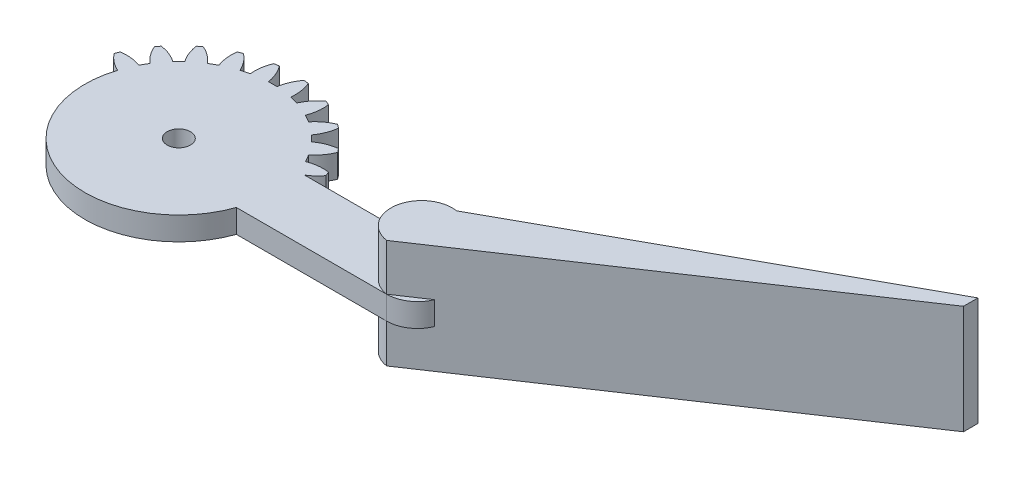
from build123d import *
from build123d.topology import SkipClean

# Parameters (mm, degrees)
SKETCH1_R                = 1.5
BOSS_EXTRUDE1_DEPTH      = 3
CUT_EXTRUDE1_START       = -10
CUT_EXTRUDE1_DEPTH       = 10
BOSS_EXTRUDE2_DEPTH      = 6
BOSS_EXTRUDE2_DEPTH_BACK = 8


with BuildPart() as part:
    # Sketch1 → Boss-Extrude1 (new body)
    with BuildSketch(Plane(origin=(0, 0, 0), x_dir=(1, 0, 0), z_dir=(0, 1, 0))):
        with BuildLine():
            Line((20.643657446, 4), (2.081641936, 4))
            ThreePointArc((2.081641936, 4), (2.861028333, 4.588201733), (3.521749436, 5.30713988))
            ThreePointArc((3.521749436, 5.30713988), (3.405395609, 5.596745198), (3.282888305, 5.883801663))
            ThreePointArc((3.282888305, 5.883801663), (1.93527598, 5.894040025), (0.627094961, 5.57027124))
            ThreePointArc((0.627094961, 5.57027124), (0.366286148, 6.046375), (0.084372603, 6.510293938))
            ThreePointArc((0.084372603, 6.510293938), (1.018855105, 7.48132754), (1.683794586, 8.65351323))
            ThreePointArc((1.683794586, 8.65351323), (1.496450048, 8.903135899), (1.303821399, 9.148703928))
            ThreePointArc((1.303821399, 9.148703928), (-0.000522033, 8.809805691), (-1.180330337, 8.158486898))
            ThreePointArc((-1.180330337, 8.158486898), (-1.555477026, 8.550865528), (-1.947855656, 8.926012217))
            ThreePointArc((-1.947855656, 8.926012217), (-1.296536862, 10.105820521), (-0.957638625, 11.410163953))
            ThreePointArc((-0.957638625, 11.410163953), (-1.203206655, 11.602792602), (-1.452829324, 11.79013714))
            ThreePointArc((-1.452829324, 11.79013714), (-2.625015014, 11.125197659), (-3.596048616, 10.190715157))
            ThreePointArc((-3.596048616, 10.190715157), (-4.059967554, 10.472628702), (-4.536071314, 10.733437515))
            ThreePointArc((-4.536071314, 10.733437515), (-4.212302529, 12.041618533), (-4.222540891, 13.389230859))
            ThreePointArc((-4.222540891, 13.389230859), (-4.509597355, 13.511738163), (-4.799202674, 13.62809199))
            ThreePointArc((-4.799202674, 13.62809199), (-5.759348103, 12.682425791), (-6.455432668, 11.528463019))
            ThreePointArc((-6.455432668, 11.528463019), (-6.976508546, 11.680699536), (-7.503891752, 11.809396783))
            ThreePointArc((-7.503891752, 11.809396783), (-7.529737283, 13.156800143), (-7.888414517, 14.455843809))
            ThreePointArc((-7.888414517, 14.455843809), (-8.197396993, 14.499881098), (-8.507248835, 14.537314892))
            ThreePointArc((-8.507248835, 14.537314892), (-9.18992168, 13.375367565), (-9.563620196, 12.080565177))
            ThreePointArc((-9.563620196, 12.080565177), (-10.106342554, 12.09275), (-10.649064912, 12.080565177))
            ThreePointArc((-10.649064912, 12.080565177), (-11.022763428, 13.375367565), (-11.705436272, 14.537314892))
            ThreePointArc((-11.705436272, 14.537314892), (-12.015288115, 14.499881098), (-12.324270591, 14.455843809))
            ThreePointArc((-12.324270591, 14.455843809), (-12.682947825, 13.156800143), (-12.708793355, 11.809396783))
            ThreePointArc((-12.708793355, 11.809396783), (-13.236176561, 11.680699536), (-13.757252439, 11.528463019))
            ThreePointArc((-13.757252439, 11.528463019), (-14.453337005, 12.682425791), (-15.413482434, 13.62809199))
            ThreePointArc((-15.413482434, 13.62809199), (-15.703087752, 13.511738163), (-15.990144217, 13.389230859))
            ThreePointArc((-15.990144217, 13.389230859), (-16.000382579, 12.041618533), (-15.676613793, 10.733437515))
            ThreePointArc((-15.676613793, 10.733437515), (-16.152717554, 10.472628702), (-16.616636492, 10.190715157))
            ThreePointArc((-16.616636492, 10.190715157), (-17.587670094, 11.125197659), (-18.759855783, 11.79013714))
            ThreePointArc((-18.759855783, 11.79013714), (-19.009478453, 11.602792602), (-19.255046482, 11.410163953))
            ThreePointArc((-19.255046482, 11.410163953), (-18.916148245, 10.105820521), (-18.264829452, 8.926012217))
            ThreePointArc((-18.264829452, 8.926012217), (-18.657208082, 8.550865528), (-19.032354771, 8.158486898))
            ThreePointArc((-19.032354771, 8.158486898), (-20.212163074, 8.809805691), (-21.516506507, 9.148703928))
            ThreePointArc((-21.516506507, 9.148703928), (-21.709135156, 8.903135899), (-21.896479694, 8.65351323))
            ThreePointArc((-21.896479694, 8.65351323), (-21.231540213, 7.48132754), (-20.297057711, 6.510293938))
            ThreePointArc((-20.297057711, 6.510293938), (-20.578971255, 6.046375), (-20.839780068, 5.57027124))
            ThreePointArc((-20.839780068, 5.57027124), (-22.147961087, 5.894040025), (-23.495573413, 5.883801663))
            ThreePointArc((-23.495573413, 5.883801663), (-23.618080717, 5.596745198), (-23.734434544, 5.30713988))
            ThreePointArc((-23.734434544, 5.30713988), (-22.788768345, 4.346994451), (-21.634805572, 3.650909885))
            ThreePointArc((-21.634805572, 3.650909885), (-21.78704209, 3.129834008), (-21.915739337, 2.602450802))
            ThreePointArc((-21.915739337, 2.602450802), (-23.263142697, 2.576605271), (-24.562186363, 2.217928037))
            ThreePointArc((-24.562186363, 2.217928037), (-24.606223651, 1.908945561), (-24.643657446, 1.599093719))
            ThreePointArc((-24.643657446, 1.599093719), (-23.481710119, 0.916420874), (-22.186907731, 0.542722358))
            ThreePointArc((-22.186907731, 0.542722358), (-22.199092554, 0), (-22.186907731, -0.542722358))
            ThreePointArc((-22.186907731, -0.542722358), (-23.481710119, -0.916420874), (-24.643657446, -1.599093719))
            ThreePointArc((-24.643657446, -1.599093719), (-24.606223651, -1.908945561), (-24.562186363, -2.217928037))
            ThreePointArc((-24.562186363, -2.217928037), (-23.263142697, -2.576605271), (-21.915739337, -2.602450802))
            ThreePointArc((-21.915739337, -2.602450802), (-21.78704209, -3.129834008), (-21.634805572, -3.650909885))
            ThreePointArc((-21.634805572, -3.650909885), (-22.788768345, -4.346994451), (-23.734434544, -5.30713988))
            ThreePointArc((-23.734434544, -5.30713988), (-23.618080717, -5.596745198), (-23.495573413, -5.883801663))
            ThreePointArc((-23.495573413, -5.883801663), (-22.147961087, -5.894040025), (-20.839780068, -5.57027124))
            ThreePointArc((-20.839780068, -5.57027124), (-20.578971255, -6.046375), (-20.297057711, -6.510293938))
            ThreePointArc((-20.297057711, -6.510293938), (-21.231540213, -7.48132754), (-21.896479694, -8.65351323))
            ThreePointArc((-21.896479694, -8.65351323), (-21.709135156, -8.903135899), (-21.516506507, -9.148703928))
            ThreePointArc((-21.516506507, -9.148703928), (-20.212163074, -8.809805691), (-19.032354771, -8.158486898))
            ThreePointArc((-19.032354771, -8.158486898), (-18.657208082, -8.550865528), (-18.264829452, -8.926012217))
            ThreePointArc((-18.264829452, -8.926012217), (-18.916148245, -10.105820521), (-19.255046482, -11.410163953))
            ThreePointArc((-19.255046482, -11.410163953), (-19.009478453, -11.602792602), (-18.759855783, -11.79013714))
            ThreePointArc((-18.759855783, -11.79013714), (-17.587670094, -11.125197659), (-16.616636492, -10.190715157))
            ThreePointArc((-16.616636492, -10.190715157), (-16.152717554, -10.472628702), (-15.676613793, -10.733437515))
            ThreePointArc((-15.676613793, -10.733437515), (-16.000382579, -12.041618533), (-15.990144217, -13.389230859))
            ThreePointArc((-15.990144217, -13.389230859), (-15.703087752, -13.511738163), (-15.413482434, -13.62809199))
            ThreePointArc((-15.413482434, -13.62809199), (-14.453337005, -12.682425791), (-13.757252439, -11.528463019))
            ThreePointArc((-13.757252439, -11.528463019), (-13.236176561, -11.680699536), (-12.708793355, -11.809396783))
            ThreePointArc((-12.708793355, -11.809396783), (-12.682947825, -13.156800143), (-12.324270591, -14.455843809))
            ThreePointArc((-12.324270591, -14.455843809), (-12.015288115, -14.499881098), (-11.705436272, -14.537314892))
            ThreePointArc((-11.705436272, -14.537314892), (-11.022763428, -13.375367565), (-10.649064912, -12.080565177))
            ThreePointArc((-10.649064912, -12.080565177), (-10.106342554, -12.09275), (-9.563620196, -12.080565177))
            ThreePointArc((-9.563620196, -12.080565177), (-9.18992168, -13.375367565), (-8.507248835, -14.537314892))
            ThreePointArc((-8.507248835, -14.537314892), (-8.197396993, -14.499881098), (-7.888414517, -14.455843809))
            ThreePointArc((-7.888414517, -14.455843809), (-7.529737283, -13.156800143), (-7.503891752, -11.809396783))
            ThreePointArc((-7.503891752, -11.809396783), (-6.976508546, -11.680699536), (-6.455432668, -11.528463019))
            ThreePointArc((-6.455432668, -11.528463019), (-5.759348103, -12.682425791), (-4.799202674, -13.62809199))
            ThreePointArc((-4.799202674, -13.62809199), (-4.509597355, -13.511738163), (-4.222540891, -13.389230859))
            ThreePointArc((-4.222540891, -13.389230859), (-4.212302529, -12.041618533), (-4.536071314, -10.733437515))
            ThreePointArc((-4.536071314, -10.733437515), (-4.059967554, -10.472628702), (-3.596048616, -10.190715157))
            ThreePointArc((-3.596048616, -10.190715157), (-2.625015014, -11.125197659), (-1.452829324, -11.79013714))
            ThreePointArc((-1.452829324, -11.79013714), (-1.203206655, -11.602792602), (-0.957638625, -11.410163953))
            ThreePointArc((-0.957638625, -11.410163953), (-1.296536862, -10.105820521), (-1.947855656, -8.926012217))
            ThreePointArc((-1.947855656, -8.926012217), (-1.555477026, -8.550865528), (-1.180330337, -8.158486898))
            ThreePointArc((-1.180330337, -8.158486898), (-0.000522033, -8.809805691), (1.303821399, -9.148703928))
            ThreePointArc((1.303821399, -9.148703928), (1.496450048, -8.903135899), (1.683794586, -8.65351323))
            ThreePointArc((1.683794586, -8.65351323), (1.018855105, -7.48132754), (0.084372603, -6.510293938))
            ThreePointArc((0.084372603, -6.510293938), (0.366286148, -6.046375), (0.627094961, -5.57027124))
            ThreePointArc((0.627094961, -5.57027124), (1.93527598, -5.894040025), (3.282888305, -5.883801663))
            ThreePointArc((3.282888305, -5.883801663), (3.405395609, -5.596745198), (3.521749436, -5.30713988))
            ThreePointArc((3.521749436, -5.30713988), (2.861028333, -4.588201733), (2.081641936, -4))
            Line((2.081641936, -4), (20.643657446, -4))
            ThreePointArc((20.643657446, -4), (24.643657446, 0), (20.643657446, 4))
        make_face()
        with Locations((-10.106342554, 0)):
            Circle(SKETCH1_R, mode=Mode.SUBTRACT)
        with Locations((20.643657446, 0)):
            Circle(SKETCH1_R, mode=Mode.SUBTRACT)
    extrude(amount=BOSS_EXTRUDE1_DEPTH)

    # Sketch2 → Cut-Extrude1 (cut)
    with SkipClean():  # the faces are left unmerged after this step: merging them gives an invalid solid
        with BuildSketch(Plane(origin=(0, 3, 0), x_dir=(1, 0, 0), z_dir=(0, 1, 0)).offset(CUT_EXTRUDE1_START)):
            with BuildLine():
                ThreePointArc((3.521749436, -5.30713988), (2.861028333, -4.588201733), (2.081641936, -4))
                Line((2.081641936, -4), (1.305695063, -4))
                ThreePointArc((1.305695063, -4), (0.994195953, -4.797149927), (0.627094961, -5.57027124))
                ThreePointArc((0.627094961, -5.57027124), (1.93527598, -5.894040025), (3.282888305, -5.883801663))
                ThreePointArc((3.282888305, -5.883801663), (3.405395609, -5.596745198), (3.521749436, -5.30713988))
            make_face()
            with BuildLine():
                ThreePointArc((1.683794586, -8.65351323), (1.018855105, -7.48132754), (0.084372603, -6.510293938))
                ThreePointArc((0.084372603, -6.510293938), (-0.512518948, -7.361599771), (-1.180330337, -8.158486898))
                ThreePointArc((-1.180330337, -8.158486898), (-0.000522033, -8.809805691), (1.303821399, -9.148703928))
                ThreePointArc((1.303821399, -9.148703928), (1.496450048, -8.903135899), (1.683794586, -8.65351323))
            make_face()
            with BuildLine():
                ThreePointArc((-0.957638625, -11.410163953), (-1.296536862, -10.105820521), (-1.947855656, -8.926012217))
                ThreePointArc((-1.947855656, -8.926012217), (-2.744742783, -9.593823606), (-3.596048616, -10.190715157))
                ThreePointArc((-3.596048616, -10.190715157), (-2.625015014, -11.125197659), (-1.452829324, -11.79013714))
                ThreePointArc((-1.452829324, -11.79013714), (-1.203206655, -11.602792602), (-0.957638625, -11.410163953))
            make_face()
            with BuildLine():
                ThreePointArc((-4.222540891, -13.389230859), (-4.212302529, -12.041618533), (-4.536071314, -10.733437515))
                ThreePointArc((-4.536071314, -10.733437515), (-5.478647477, -11.172244217), (-6.455432668, -11.528463019))
                ThreePointArc((-6.455432668, -11.528463019), (-5.759348103, -12.682425791), (-4.799202674, -13.62809199))
                ThreePointArc((-4.799202674, -13.62809199), (-4.509597355, -13.511738163), (-4.222540891, -13.389230859))
            make_face()
            with BuildLine():
                ThreePointArc((-7.888414517, -14.455843809), (-7.529737283, -13.156800143), (-7.503891752, -11.809396783))
                ThreePointArc((-7.503891752, -11.809396783), (-8.527921943, -11.989294847), (-9.563620196, -12.080565177))
                ThreePointArc((-9.563620196, -12.080565177), (-9.18992168, -13.375367565), (-8.507248835, -14.537314892))
                ThreePointArc((-8.507248835, -14.537314892), (-8.197396993, -14.499881098), (-7.888414517, -14.455843809))
            make_face()
            with BuildLine():
                ThreePointArc((-11.705436272, -14.537314892), (-11.022763428, -13.375367565), (-10.649064912, -12.080565177))
                ThreePointArc((-10.649064912, -12.080565177), (-11.684763165, -11.989294847), (-12.708793355, -11.809396783))
                ThreePointArc((-12.708793355, -11.809396783), (-12.682947825, -13.156800143), (-12.324270591, -14.455843809))
                ThreePointArc((-12.324270591, -14.455843809), (-12.015288115, -14.499881098), (-11.705436272, -14.537314892))
            make_face()
            with BuildLine():
                ThreePointArc((-15.413482434, -13.62809199), (-14.453337005, -12.682425791), (-13.757252439, -11.528463019))
                ThreePointArc((-13.757252439, -11.528463019), (-14.734037631, -11.172244217), (-15.676613793, -10.733437515))
                ThreePointArc((-15.676613793, -10.733437515), (-16.000382579, -12.041618533), (-15.990144217, -13.389230859))
                ThreePointArc((-15.990144217, -13.389230859), (-15.703087752, -13.511738163), (-15.413482434, -13.62809199))
            make_face()
            with BuildLine():
                ThreePointArc((-18.759855783, -11.79013714), (-17.587670094, -11.125197659), (-16.616636492, -10.190715157))
                ThreePointArc((-16.616636492, -10.190715157), (-17.467942324, -9.593823606), (-18.264829452, -8.926012217))
                ThreePointArc((-18.264829452, -8.926012217), (-18.916148245, -10.105820521), (-19.255046482, -11.410163953))
                ThreePointArc((-19.255046482, -11.410163953), (-19.009478453, -11.602792602), (-18.759855783, -11.79013714))
            make_face()
            with BuildLine():
                ThreePointArc((-21.516506507, -9.148703928), (-20.212163074, -8.809805691), (-19.032354771, -8.158486898))
                ThreePointArc((-19.032354771, -8.158486898), (-19.70016616, -7.361599771), (-20.297057711, -6.510293938))
                ThreePointArc((-20.297057711, -6.510293938), (-21.231540213, -7.48132754), (-21.896479694, -8.65351323))
                ThreePointArc((-21.896479694, -8.65351323), (-21.709135156, -8.903135899), (-21.516506507, -9.148703928))
            make_face()
            with BuildLine():
                ThreePointArc((-23.495573413, -5.883801663), (-22.147961087, -5.894040025), (-20.839780068, -5.57027124))
                ThreePointArc((-20.839780068, -5.57027124), (-21.278586771, -4.627695077), (-21.634805572, -3.650909885))
                ThreePointArc((-21.634805572, -3.650909885), (-22.788768345, -4.346994451), (-23.734434544, -5.30713988))
                ThreePointArc((-23.734434544, -5.30713988), (-23.618080717, -5.596745198), (-23.495573413, -5.883801663))
            make_face()
            with BuildLine():
                ThreePointArc((-24.562186363, -2.217928037), (-23.263142697, -2.576605271), (-21.915739337, -2.602450802))
                ThreePointArc((-21.915739337, -2.602450802), (-22.095637401, -1.578420611), (-22.186907731, -0.542722358))
                ThreePointArc((-22.186907731, -0.542722358), (-23.481710119, -0.916420874), (-24.643657446, -1.599093719))
                ThreePointArc((-24.643657446, -1.599093719), (-24.606223651, -1.908945561), (-24.562186363, -2.217928037))
            make_face()
            with BuildLine():
                ThreePointArc((-22.186907731, 0.542722358), (-22.095637401, 1.578420611), (-21.915739337, 2.602450802))
                ThreePointArc((-21.915739337, 2.602450802), (-23.263142697, 2.576605271), (-24.562186363, 2.217928037))
                ThreePointArc((-24.562186363, 2.217928037), (-24.606223651, 1.908945561), (-24.643657446, 1.599093719))
                ThreePointArc((-24.643657446, 1.599093719), (-23.481710119, 0.916420874), (-22.186907731, 0.542722358))
            make_face()
        extrude(amount=CUT_EXTRUDE1_DEPTH, mode=Mode.SUBTRACT)

    # Sketch3 → Boss-Extrude2 (add, two sides: drawn at the far end of the back side and taken through both)
    with SkipClean():  # the faces are left unmerged after this step: merging them gives an invalid solid
        with BuildSketch(Plane(origin=(0, 3, 0), x_dir=(1, 0, 0), z_dir=(0, 1, 0)).offset(-BOSS_EXTRUDE2_DEPTH_BACK)):
            with BuildLine():
                Line((21.863468117, 3.809470032), (65.125813964, 27.66054744))
                Line((65.125813964, 27.66054744), (65.125813964, 25.790000621))
                Line((65.125813964, 25.790000621), (20.643657446, -4))
                ThreePointArc((20.643657446, -4), (17.348827766, 0.514640352), (21.863468117, 3.809470032))
            make_face()
        extrude(amount=BOSS_EXTRUDE2_DEPTH + BOSS_EXTRUDE2_DEPTH_BACK)


solid = part.part
